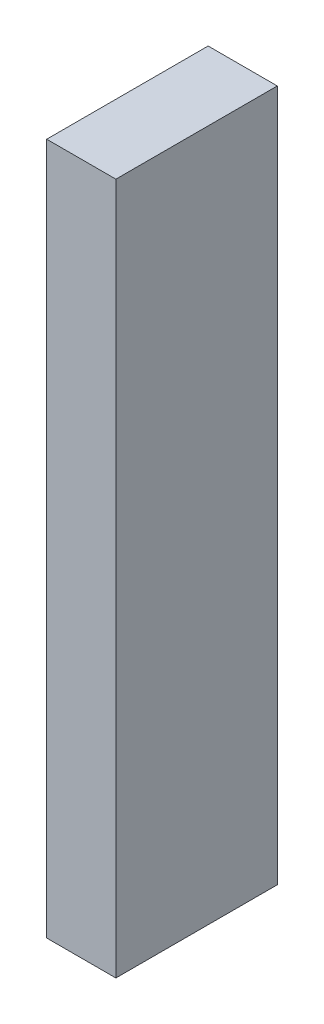
from build123d import *

# Parameters (mm, degrees)
SKETCH1_W           = 3
SKETCH1_H           = 7
BOSS_EXTRUDE1_DEPTH = 30


with BuildPart() as part:
    # Sketch1 → Boss-Extrude1 (new body)
    with BuildSketch(Plane(origin=(0, 0, 0), x_dir=(1, 0, 0), z_dir=(0, 1, 0))):
        with Locations((-24.006873678, -26.608014532)):
            Rectangle(SKETCH1_W, SKETCH1_H)
    extrude(amount=BOSS_EXTRUDE1_DEPTH)


solid = part.part
